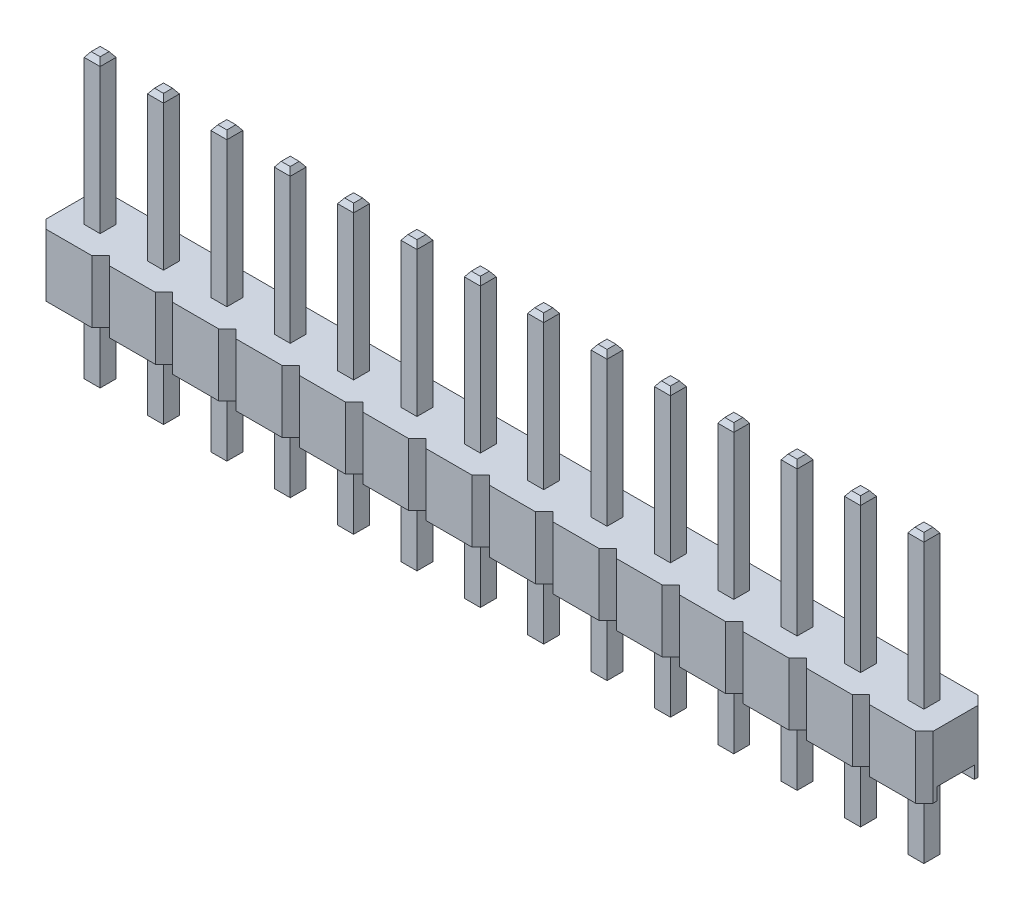
from build123d import *
from OCP.BRepFilletAPI import BRepFilletAPI_MakeChamfer

# Parameters (mm, degrees)
BOSS_EXTRUDE1_DEPTH         = 2.5
SKETCH3_W                   = 2.54
SKETCH3_H                   = 1.5
CUT_EXTRUDE1_DEPTH          = 0.5
BOSS_EXTRUDE2_START         = -5.5
SKETCH4_W                   = 0.64
SKETCH4_H                   = 0.64
BOSS_EXTRUDE2_DEPTH         = 11.5
CHAMFER1_SIZE               = 0.2
CHAMFER1_SIZE2              = 0.140041508
LPATTERN3_COUNT             = 14
LPATTERN3_PITCH             = 2.54
CHAMFER1_OF_LPATTERN3_SIZE  = 0.2
CHAMFER1_OF_LPATTERN3_SIZE2 = 0.140041508


with BuildPart() as part:
    # Sketch1 → Boss-Extrude1 (new body)
    with BuildSketch(Plane(origin=(0, 0, 0), x_dir=(1, 0, 0), z_dir=(0, 1, 0))):
        Polygon((0, 2.15), (0.35, 2.5), (2.19, 2.5), (2.54, 2.15), (2.54, 0.35), (2.19, 0), (0.35, 0), (0, 0.35), align=None)
    boss_extrude1 = extrude(amount=BOSS_EXTRUDE1_DEPTH)

    # Sketch3 → Cut-Extrude1 (cut)
    with BuildSketch(Plane.XZ):
        with Locations((1.27, -1.25)):
            Rectangle(SKETCH3_W, SKETCH3_H)
    cut_extrude1 = extrude(amount=-CUT_EXTRUDE1_DEPTH, mode=Mode.SUBTRACT)

    # Sketch4 → Boss-Extrude2 (add)
    with BuildSketch(Plane(origin=(0, 2.5, 0), x_dir=(1, 0, 0), z_dir=(0, 1, 0)).offset(BOSS_EXTRUDE2_START)):
        with Locations((1.27, 1.25)):
            Rectangle(SKETCH4_W, SKETCH4_H)
    boss_extrude2 = extrude(amount=BOSS_EXTRUDE2_DEPTH)

    # Chamfer1: one chamfer whose edges measure the first distance from different faces: ONE call of the kernel's chamfer builder (chamfer() names one face for all edges)
    chamfer1_edges_1 = [part.edges().sort_by_distance(p)[0] for p in [
        (1.59, -3, -1.25),
        (1.27, -3, -0.93),
        (0.95, -3, -1.25),
        (1.27, -3, -1.57),
    ]]
    chamfer1_side_1 = [part.faces().sort_by_distance(p)[0] for p in [
        (1.27, -3, -1.25),
    ]]
    chamfer1_edges_2 = [part.edges().sort_by_distance(p)[0] for p in [
        (1.59, 8.5, -1.25),
    ]]
    chamfer1_side_2 = [part.faces().sort_by_distance(p)[0] for p in [
        (1.59, 5.5, -1.25),
    ]]
    chamfer1_edges_3 = [part.edges().sort_by_distance(p)[0] for p in [
        (1.27, 8.5, -1.57),
    ]]
    chamfer1_side_3 = [part.faces().sort_by_distance(p)[0] for p in [
        (1.27, 5.5, -1.57),
    ]]
    chamfer1_edges_4 = [part.edges().sort_by_distance(p)[0] for p in [
        (0.95, 8.5, -1.25),
    ]]
    chamfer1_side_4 = [part.faces().sort_by_distance(p)[0] for p in [
        (0.95, 5.5, -1.25),
    ]]
    chamfer1_edges_5 = [part.edges().sort_by_distance(p)[0] for p in [
        (1.27, 8.5, -0.93),
    ]]
    chamfer1_side_5 = [part.faces().sort_by_distance(p)[0] for p in [
        (1.27, 5.5, -0.93),
    ]]
    chamfer1 = BRepFilletAPI_MakeChamfer(part.part.solid().wrapped)
    for e in chamfer1_edges_1:
        chamfer1.Add(CHAMFER1_SIZE, CHAMFER1_SIZE2, e.wrapped, chamfer1_side_1[0].wrapped)  # the first distance lies on this face
    for e in chamfer1_edges_2:
        chamfer1.Add(CHAMFER1_SIZE, CHAMFER1_SIZE2, e.wrapped, chamfer1_side_2[0].wrapped)  # the first distance lies on this face
    for e in chamfer1_edges_3:
        chamfer1.Add(CHAMFER1_SIZE, CHAMFER1_SIZE2, e.wrapped, chamfer1_side_3[0].wrapped)  # the first distance lies on this face
    for e in chamfer1_edges_4:
        chamfer1.Add(CHAMFER1_SIZE, CHAMFER1_SIZE2, e.wrapped, chamfer1_side_4[0].wrapped)  # the first distance lies on this face
    for e in chamfer1_edges_5:
        chamfer1.Add(CHAMFER1_SIZE, CHAMFER1_SIZE2, e.wrapped, chamfer1_side_5[0].wrapped)  # the first distance lies on this face
    add(Compound.cast(chamfer1.Shape()), mode=Mode.REPLACE)

    # LPattern3: Boss-Extrude1, Cut-Extrude1, Boss-Extrude2 ×14
    with Locations(*[(-i * LPATTERN3_PITCH, 0, 0) for i in range(1, LPATTERN3_COUNT)]):
        add(boss_extrude1)
        add(cut_extrude1, mode=Mode.SUBTRACT)
        add(boss_extrude2)

    # Chamfer1 of LPattern3: one chamfer whose edges measure the first distance from different faces: ONE call of the kernel's chamfer builder (chamfer() names one face for all edges)
    chamfer1_of_lpattern3_edges_1 = [part.edges().sort_by_distance(p)[0] for p in [
        (-0.95, -3, -1.25),
        (-1.27, -3, -0.93),
        (-1.59, -3, -1.25),
        (-1.27, -3, -1.57),
    ]]
    chamfer1_of_lpattern3_side_1 = [part.faces().sort_by_distance(p)[0] for p in [
        (-1.27, -3, -1.25),
    ]]
    chamfer1_of_lpattern3_edges_2 = [part.edges().sort_by_distance(p)[0] for p in [
        (-0.95, 8.5, -1.25),
    ]]
    chamfer1_of_lpattern3_side_2 = [part.faces().sort_by_distance(p)[0] for p in [
        (-0.95, 5.5, -1.25),
    ]]
    chamfer1_of_lpattern3_edges_3 = [part.edges().sort_by_distance(p)[0] for p in [
        (-1.27, 8.5, -1.57),
    ]]
    chamfer1_of_lpattern3_side_3 = [part.faces().sort_by_distance(p)[0] for p in [
        (-1.27, 5.5, -1.57),
    ]]
    chamfer1_of_lpattern3_edges_4 = [part.edges().sort_by_distance(p)[0] for p in [
        (-1.59, 8.5, -1.25),
    ]]
    chamfer1_of_lpattern3_side_4 = [part.faces().sort_by_distance(p)[0] for p in [
        (-1.59, 5.5, -1.25),
    ]]
    chamfer1_of_lpattern3_edges_5 = [part.edges().sort_by_distance(p)[0] for p in [
        (-1.27, 8.5, -0.93),
    ]]
    chamfer1_of_lpattern3_side_5 = [part.faces().sort_by_distance(p)[0] for p in [
        (-1.27, 5.5, -0.93),
    ]]
    chamfer1_of_lpattern3_edges_6 = [part.edges().sort_by_distance(p)[0] for p in [
        (-3.49, -3, -1.25),
        (-3.81, -3, -0.93),
        (-4.13, -3, -1.25),
        (-3.81, -3, -1.57),
    ]]
    chamfer1_of_lpattern3_side_6 = [part.faces().sort_by_distance(p)[0] for p in [
        (-3.81, -3, -1.25),
    ]]
    chamfer1_of_lpattern3_edges_7 = [part.edges().sort_by_distance(p)[0] for p in [
        (-3.49, 8.5, -1.25),
    ]]
    chamfer1_of_lpattern3_side_7 = [part.faces().sort_by_distance(p)[0] for p in [
        (-3.49, 5.5, -1.25),
    ]]
    chamfer1_of_lpattern3_edges_8 = [part.edges().sort_by_distance(p)[0] for p in [
        (-3.81, 8.5, -1.57),
    ]]
    chamfer1_of_lpattern3_side_8 = [part.faces().sort_by_distance(p)[0] for p in [
        (-3.81, 5.5, -1.57),
    ]]
    chamfer1_of_lpattern3_edges_9 = [part.edges().sort_by_distance(p)[0] for p in [
        (-4.13, 8.5, -1.25),
    ]]
    chamfer1_of_lpattern3_side_9 = [part.faces().sort_by_distance(p)[0] for p in [
        (-4.13, 5.5, -1.25),
    ]]
    chamfer1_of_lpattern3_edges_10 = [part.edges().sort_by_distance(p)[0] for p in [
        (-3.81, 8.5, -0.93),
    ]]
    chamfer1_of_lpattern3_side_10 = [part.faces().sort_by_distance(p)[0] for p in [
        (-3.81, 5.5, -0.93),
    ]]
    chamfer1_of_lpattern3_edges_11 = [part.edges().sort_by_distance(p)[0] for p in [
        (-6.03, -3, -1.25),
        (-6.35, -3, -0.93),
        (-6.67, -3, -1.25),
        (-6.35, -3, -1.57),
    ]]
    chamfer1_of_lpattern3_side_11 = [part.faces().sort_by_distance(p)[0] for p in [
        (-6.35, -3, -1.25),
    ]]
    chamfer1_of_lpattern3_edges_12 = [part.edges().sort_by_distance(p)[0] for p in [
        (-6.03, 8.5, -1.25),
    ]]
    chamfer1_of_lpattern3_side_12 = [part.faces().sort_by_distance(p)[0] for p in [
        (-6.03, 5.5, -1.25),
    ]]
    chamfer1_of_lpattern3_edges_13 = [part.edges().sort_by_distance(p)[0] for p in [
        (-6.35, 8.5, -1.57),
    ]]
    chamfer1_of_lpattern3_side_13 = [part.faces().sort_by_distance(p)[0] for p in [
        (-6.35, 5.5, -1.57),
    ]]
    chamfer1_of_lpattern3_edges_14 = [part.edges().sort_by_distance(p)[0] for p in [
        (-6.67, 8.5, -1.25),
    ]]
    chamfer1_of_lpattern3_side_14 = [part.faces().sort_by_distance(p)[0] for p in [
        (-6.67, 5.5, -1.25),
    ]]
    chamfer1_of_lpattern3_edges_15 = [part.edges().sort_by_distance(p)[0] for p in [
        (-6.35, 8.5, -0.93),
    ]]
    chamfer1_of_lpattern3_side_15 = [part.faces().sort_by_distance(p)[0] for p in [
        (-6.35, 5.5, -0.93),
    ]]
    chamfer1_of_lpattern3_edges_16 = [part.edges().sort_by_distance(p)[0] for p in [
        (-8.57, -3, -1.25),
        (-8.89, -3, -0.93),
        (-9.21, -3, -1.25),
        (-8.89, -3, -1.57),
    ]]
    chamfer1_of_lpattern3_side_16 = [part.faces().sort_by_distance(p)[0] for p in [
        (-8.89, -3, -1.25),
    ]]
    chamfer1_of_lpattern3_edges_17 = [part.edges().sort_by_distance(p)[0] for p in [
        (-8.57, 8.5, -1.25),
    ]]
    chamfer1_of_lpattern3_side_17 = [part.faces().sort_by_distance(p)[0] for p in [
        (-8.57, 5.5, -1.25),
    ]]
    chamfer1_of_lpattern3_edges_18 = [part.edges().sort_by_distance(p)[0] for p in [
        (-8.89, 8.5, -1.57),
    ]]
    chamfer1_of_lpattern3_side_18 = [part.faces().sort_by_distance(p)[0] for p in [
        (-8.89, 5.5, -1.57),
    ]]
    chamfer1_of_lpattern3_edges_19 = [part.edges().sort_by_distance(p)[0] for p in [
        (-9.21, 8.5, -1.25),
    ]]
    chamfer1_of_lpattern3_side_19 = [part.faces().sort_by_distance(p)[0] for p in [
        (-9.21, 5.5, -1.25),
    ]]
    chamfer1_of_lpattern3_edges_20 = [part.edges().sort_by_distance(p)[0] for p in [
        (-8.89, 8.5, -0.93),
    ]]
    chamfer1_of_lpattern3_side_20 = [part.faces().sort_by_distance(p)[0] for p in [
        (-8.89, 5.5, -0.93),
    ]]
    chamfer1_of_lpattern3_edges_21 = [part.edges().sort_by_distance(p)[0] for p in [
        (-11.11, -3, -1.25),
        (-11.43, -3, -0.93),
        (-11.75, -3, -1.25),
        (-11.43, -3, -1.57),
    ]]
    chamfer1_of_lpattern3_side_21 = [part.faces().sort_by_distance(p)[0] for p in [
        (-11.43, -3, -1.25),
    ]]
    chamfer1_of_lpattern3_edges_22 = [part.edges().sort_by_distance(p)[0] for p in [
        (-11.11, 8.5, -1.25),
    ]]
    chamfer1_of_lpattern3_side_22 = [part.faces().sort_by_distance(p)[0] for p in [
        (-11.11, 5.5, -1.25),
    ]]
    chamfer1_of_lpattern3_edges_23 = [part.edges().sort_by_distance(p)[0] for p in [
        (-11.43, 8.5, -1.57),
    ]]
    chamfer1_of_lpattern3_side_23 = [part.faces().sort_by_distance(p)[0] for p in [
        (-11.43, 5.5, -1.57),
    ]]
    chamfer1_of_lpattern3_edges_24 = [part.edges().sort_by_distance(p)[0] for p in [
        (-11.75, 8.5, -1.25),
    ]]
    chamfer1_of_lpattern3_side_24 = [part.faces().sort_by_distance(p)[0] for p in [
        (-11.75, 5.5, -1.25),
    ]]
    chamfer1_of_lpattern3_edges_25 = [part.edges().sort_by_distance(p)[0] for p in [
        (-11.43, 8.5, -0.93),
    ]]
    chamfer1_of_lpattern3_side_25 = [part.faces().sort_by_distance(p)[0] for p in [
        (-11.43, 5.5, -0.93),
    ]]
    chamfer1_of_lpattern3_edges_26 = [part.edges().sort_by_distance(p)[0] for p in [
        (-13.65, -3, -1.25),
        (-13.97, -3, -0.93),
        (-14.29, -3, -1.25),
        (-13.97, -3, -1.57),
    ]]
    chamfer1_of_lpattern3_side_26 = [part.faces().sort_by_distance(p)[0] for p in [
        (-13.97, -3, -1.25),
    ]]
    chamfer1_of_lpattern3_edges_27 = [part.edges().sort_by_distance(p)[0] for p in [
        (-13.65, 8.5, -1.25),
    ]]
    chamfer1_of_lpattern3_side_27 = [part.faces().sort_by_distance(p)[0] for p in [
        (-13.65, 5.5, -1.25),
    ]]
    chamfer1_of_lpattern3_edges_28 = [part.edges().sort_by_distance(p)[0] for p in [
        (-13.97, 8.5, -1.57),
    ]]
    chamfer1_of_lpattern3_side_28 = [part.faces().sort_by_distance(p)[0] for p in [
        (-13.97, 5.5, -1.57),
    ]]
    chamfer1_of_lpattern3_edges_29 = [part.edges().sort_by_distance(p)[0] for p in [
        (-14.29, 8.5, -1.25),
    ]]
    chamfer1_of_lpattern3_side_29 = [part.faces().sort_by_distance(p)[0] for p in [
        (-14.29, 5.5, -1.25),
    ]]
    chamfer1_of_lpattern3_edges_30 = [part.edges().sort_by_distance(p)[0] for p in [
        (-13.97, 8.5, -0.93),
    ]]
    chamfer1_of_lpattern3_side_30 = [part.faces().sort_by_distance(p)[0] for p in [
        (-13.97, 5.5, -0.93),
    ]]
    chamfer1_of_lpattern3_edges_31 = [part.edges().sort_by_distance(p)[0] for p in [
        (-16.19, -3, -1.25),
        (-16.51, -3, -0.93),
        (-16.83, -3, -1.25),
        (-16.51, -3, -1.57),
    ]]
    chamfer1_of_lpattern3_side_31 = [part.faces().sort_by_distance(p)[0] for p in [
        (-16.51, -3, -1.25),
    ]]
    chamfer1_of_lpattern3_edges_32 = [part.edges().sort_by_distance(p)[0] for p in [
        (-16.19, 8.5, -1.25),
    ]]
    chamfer1_of_lpattern3_side_32 = [part.faces().sort_by_distance(p)[0] for p in [
        (-16.19, 5.5, -1.25),
    ]]
    chamfer1_of_lpattern3_edges_33 = [part.edges().sort_by_distance(p)[0] for p in [
        (-16.51, 8.5, -1.57),
    ]]
    chamfer1_of_lpattern3_side_33 = [part.faces().sort_by_distance(p)[0] for p in [
        (-16.51, 5.5, -1.57),
    ]]
    chamfer1_of_lpattern3_edges_34 = [part.edges().sort_by_distance(p)[0] for p in [
        (-16.83, 8.5, -1.25),
    ]]
    chamfer1_of_lpattern3_side_34 = [part.faces().sort_by_distance(p)[0] for p in [
        (-16.83, 5.5, -1.25),
    ]]
    chamfer1_of_lpattern3_edges_35 = [part.edges().sort_by_distance(p)[0] for p in [
        (-16.51, 8.5, -0.93),
    ]]
    chamfer1_of_lpattern3_side_35 = [part.faces().sort_by_distance(p)[0] for p in [
        (-16.51, 5.5, -0.93),
    ]]
    chamfer1_of_lpattern3_edges_36 = [part.edges().sort_by_distance(p)[0] for p in [
        (-18.73, -3, -1.25),
        (-19.05, -3, -0.93),
        (-19.37, -3, -1.25),
        (-19.05, -3, -1.57),
    ]]
    chamfer1_of_lpattern3_side_36 = [part.faces().sort_by_distance(p)[0] for p in [
        (-19.05, -3, -1.25),
    ]]
    chamfer1_of_lpattern3_edges_37 = [part.edges().sort_by_distance(p)[0] for p in [
        (-18.73, 8.5, -1.25),
    ]]
    chamfer1_of_lpattern3_side_37 = [part.faces().sort_by_distance(p)[0] for p in [
        (-18.73, 5.5, -1.25),
    ]]
    chamfer1_of_lpattern3_edges_38 = [part.edges().sort_by_distance(p)[0] for p in [
        (-19.05, 8.5, -1.57),
    ]]
    chamfer1_of_lpattern3_side_38 = [part.faces().sort_by_distance(p)[0] for p in [
        (-19.05, 5.5, -1.57),
    ]]
    chamfer1_of_lpattern3_edges_39 = [part.edges().sort_by_distance(p)[0] for p in [
        (-19.37, 8.5, -1.25),
    ]]
    chamfer1_of_lpattern3_side_39 = [part.faces().sort_by_distance(p)[0] for p in [
        (-19.37, 5.5, -1.25),
    ]]
    chamfer1_of_lpattern3_edges_40 = [part.edges().sort_by_distance(p)[0] for p in [
        (-19.05, 8.5, -0.93),
    ]]
    chamfer1_of_lpattern3_side_40 = [part.faces().sort_by_distance(p)[0] for p in [
        (-19.05, 5.5, -0.93),
    ]]
    chamfer1_of_lpattern3_edges_41 = [part.edges().sort_by_distance(p)[0] for p in [
        (-21.27, -3, -1.25),
        (-21.59, -3, -0.93),
        (-21.91, -3, -1.25),
        (-21.59, -3, -1.57),
    ]]
    chamfer1_of_lpattern3_side_41 = [part.faces().sort_by_distance(p)[0] for p in [
        (-21.59, -3, -1.25),
    ]]
    chamfer1_of_lpattern3_edges_42 = [part.edges().sort_by_distance(p)[0] for p in [
        (-21.27, 8.5, -1.25),
    ]]
    chamfer1_of_lpattern3_side_42 = [part.faces().sort_by_distance(p)[0] for p in [
        (-21.27, 5.5, -1.25),
    ]]
    chamfer1_of_lpattern3_edges_43 = [part.edges().sort_by_distance(p)[0] for p in [
        (-21.59, 8.5, -1.57),
    ]]
    chamfer1_of_lpattern3_side_43 = [part.faces().sort_by_distance(p)[0] for p in [
        (-21.59, 5.5, -1.57),
    ]]
    chamfer1_of_lpattern3_edges_44 = [part.edges().sort_by_distance(p)[0] for p in [
        (-21.91, 8.5, -1.25),
    ]]
    chamfer1_of_lpattern3_side_44 = [part.faces().sort_by_distance(p)[0] for p in [
        (-21.91, 5.5, -1.25),
    ]]
    chamfer1_of_lpattern3_edges_45 = [part.edges().sort_by_distance(p)[0] for p in [
        (-21.59, 8.5, -0.93),
    ]]
    chamfer1_of_lpattern3_side_45 = [part.faces().sort_by_distance(p)[0] for p in [
        (-21.59, 5.5, -0.93),
    ]]
    chamfer1_of_lpattern3_edges_46 = [part.edges().sort_by_distance(p)[0] for p in [
        (-23.81, -3, -1.25),
        (-24.13, -3, -0.93),
        (-24.45, -3, -1.25),
        (-24.13, -3, -1.57),
    ]]
    chamfer1_of_lpattern3_side_46 = [part.faces().sort_by_distance(p)[0] for p in [
        (-24.13, -3, -1.25),
    ]]
    chamfer1_of_lpattern3_edges_47 = [part.edges().sort_by_distance(p)[0] for p in [
        (-23.81, 8.5, -1.25),
    ]]
    chamfer1_of_lpattern3_side_47 = [part.faces().sort_by_distance(p)[0] for p in [
        (-23.81, 5.5, -1.25),
    ]]
    chamfer1_of_lpattern3_edges_48 = [part.edges().sort_by_distance(p)[0] for p in [
        (-24.13, 8.5, -1.57),
    ]]
    chamfer1_of_lpattern3_side_48 = [part.faces().sort_by_distance(p)[0] for p in [
        (-24.13, 5.5, -1.57),
    ]]
    chamfer1_of_lpattern3_edges_49 = [part.edges().sort_by_distance(p)[0] for p in [
        (-24.45, 8.5, -1.25),
    ]]
    chamfer1_of_lpattern3_side_49 = [part.faces().sort_by_distance(p)[0] for p in [
        (-24.45, 5.5, -1.25),
    ]]
    chamfer1_of_lpattern3_edges_50 = [part.edges().sort_by_distance(p)[0] for p in [
        (-24.13, 8.5, -0.93),
    ]]
    chamfer1_of_lpattern3_side_50 = [part.faces().sort_by_distance(p)[0] for p in [
        (-24.13, 5.5, -0.93),
    ]]
    chamfer1_of_lpattern3_edges_51 = [part.edges().sort_by_distance(p)[0] for p in [
        (-26.35, -3, -1.25),
        (-26.67, -3, -0.93),
        (-26.99, -3, -1.25),
        (-26.67, -3, -1.57),
    ]]
    chamfer1_of_lpattern3_side_51 = [part.faces().sort_by_distance(p)[0] for p in [
        (-26.67, -3, -1.25),
    ]]
    chamfer1_of_lpattern3_edges_52 = [part.edges().sort_by_distance(p)[0] for p in [
        (-26.35, 8.5, -1.25),
    ]]
    chamfer1_of_lpattern3_side_52 = [part.faces().sort_by_distance(p)[0] for p in [
        (-26.35, 5.5, -1.25),
    ]]
    chamfer1_of_lpattern3_edges_53 = [part.edges().sort_by_distance(p)[0] for p in [
        (-26.67, 8.5, -1.57),
    ]]
    chamfer1_of_lpattern3_side_53 = [part.faces().sort_by_distance(p)[0] for p in [
        (-26.67, 5.5, -1.57),
    ]]
    chamfer1_of_lpattern3_edges_54 = [part.edges().sort_by_distance(p)[0] for p in [
        (-26.99, 8.5, -1.25),
    ]]
    chamfer1_of_lpattern3_side_54 = [part.faces().sort_by_distance(p)[0] for p in [
        (-26.99, 5.5, -1.25),
    ]]
    chamfer1_of_lpattern3_edges_55 = [part.edges().sort_by_distance(p)[0] for p in [
        (-26.67, 8.5, -0.93),
    ]]
    chamfer1_of_lpattern3_side_55 = [part.faces().sort_by_distance(p)[0] for p in [
        (-26.67, 5.5, -0.93),
    ]]
    chamfer1_of_lpattern3_edges_56 = [part.edges().sort_by_distance(p)[0] for p in [
        (-28.89, -3, -1.25),
        (-29.21, -3, -0.93),
        (-29.53, -3, -1.25),
        (-29.21, -3, -1.57),
    ]]
    chamfer1_of_lpattern3_side_56 = [part.faces().sort_by_distance(p)[0] for p in [
        (-29.21, -3, -1.25),
    ]]
    chamfer1_of_lpattern3_edges_57 = [part.edges().sort_by_distance(p)[0] for p in [
        (-28.89, 8.5, -1.25),
    ]]
    chamfer1_of_lpattern3_side_57 = [part.faces().sort_by_distance(p)[0] for p in [
        (-28.89, 5.5, -1.25),
    ]]
    chamfer1_of_lpattern3_edges_58 = [part.edges().sort_by_distance(p)[0] for p in [
        (-29.21, 8.5, -1.57),
    ]]
    chamfer1_of_lpattern3_side_58 = [part.faces().sort_by_distance(p)[0] for p in [
        (-29.21, 5.5, -1.57),
    ]]
    chamfer1_of_lpattern3_edges_59 = [part.edges().sort_by_distance(p)[0] for p in [
        (-29.53, 8.5, -1.25),
    ]]
    chamfer1_of_lpattern3_side_59 = [part.faces().sort_by_distance(p)[0] for p in [
        (-29.53, 5.5, -1.25),
    ]]
    chamfer1_of_lpattern3_edges_60 = [part.edges().sort_by_distance(p)[0] for p in [
        (-29.21, 8.5, -0.93),
    ]]
    chamfer1_of_lpattern3_side_60 = [part.faces().sort_by_distance(p)[0] for p in [
        (-29.21, 5.5, -0.93),
    ]]
    chamfer1_of_lpattern3_edges_61 = [part.edges().sort_by_distance(p)[0] for p in [
        (-31.43, -3, -1.25),
        (-31.75, -3, -0.93),
        (-32.07, -3, -1.25),
        (-31.75, -3, -1.57),
    ]]
    chamfer1_of_lpattern3_side_61 = [part.faces().sort_by_distance(p)[0] for p in [
        (-31.75, -3, -1.25),
    ]]
    chamfer1_of_lpattern3_edges_62 = [part.edges().sort_by_distance(p)[0] for p in [
        (-31.43, 8.5, -1.25),
    ]]
    chamfer1_of_lpattern3_side_62 = [part.faces().sort_by_distance(p)[0] for p in [
        (-31.43, 5.5, -1.25),
    ]]
    chamfer1_of_lpattern3_edges_63 = [part.edges().sort_by_distance(p)[0] for p in [
        (-31.75, 8.5, -1.57),
    ]]
    chamfer1_of_lpattern3_side_63 = [part.faces().sort_by_distance(p)[0] for p in [
        (-31.75, 5.5, -1.57),
    ]]
    chamfer1_of_lpattern3_edges_64 = [part.edges().sort_by_distance(p)[0] for p in [
        (-32.07, 8.5, -1.25),
    ]]
    chamfer1_of_lpattern3_side_64 = [part.faces().sort_by_distance(p)[0] for p in [
        (-32.07, 5.5, -1.25),
    ]]
    chamfer1_of_lpattern3_edges_65 = [part.edges().sort_by_distance(p)[0] for p in [
        (-31.75, 8.5, -0.93),
    ]]
    chamfer1_of_lpattern3_side_65 = [part.faces().sort_by_distance(p)[0] for p in [
        (-31.75, 5.5, -0.93),
    ]]
    chamfer1_of_lpattern3 = BRepFilletAPI_MakeChamfer(part.part.solid().wrapped)
    for e in chamfer1_of_lpattern3_edges_1:
        chamfer1_of_lpattern3.Add(CHAMFER1_OF_LPATTERN3_SIZE, CHAMFER1_OF_LPATTERN3_SIZE2, e.wrapped, chamfer1_of_lpattern3_side_1[0].wrapped)  # the first distance lies on this face
    for e in chamfer1_of_lpattern3_edges_2:
        chamfer1_of_lpattern3.Add(CHAMFER1_OF_LPATTERN3_SIZE, CHAMFER1_OF_LPATTERN3_SIZE2, e.wrapped, chamfer1_of_lpattern3_side_2[0].wrapped)  # the first distance lies on this face
    for e in chamfer1_of_lpattern3_edges_3:
        chamfer1_of_lpattern3.Add(CHAMFER1_OF_LPATTERN3_SIZE, CHAMFER1_OF_LPATTERN3_SIZE2, e.wrapped, chamfer1_of_lpattern3_side_3[0].wrapped)  # the first distance lies on this face
    for e in chamfer1_of_lpattern3_edges_4:
        chamfer1_of_lpattern3.Add(CHAMFER1_OF_LPATTERN3_SIZE, CHAMFER1_OF_LPATTERN3_SIZE2, e.wrapped, chamfer1_of_lpattern3_side_4[0].wrapped)  # the first distance lies on this face
    for e in chamfer1_of_lpattern3_edges_5:
        chamfer1_of_lpattern3.Add(CHAMFER1_OF_LPATTERN3_SIZE, CHAMFER1_OF_LPATTERN3_SIZE2, e.wrapped, chamfer1_of_lpattern3_side_5[0].wrapped)  # the first distance lies on this face
    for e in chamfer1_of_lpattern3_edges_6:
        chamfer1_of_lpattern3.Add(CHAMFER1_OF_LPATTERN3_SIZE, CHAMFER1_OF_LPATTERN3_SIZE2, e.wrapped, chamfer1_of_lpattern3_side_6[0].wrapped)  # the first distance lies on this face
    for e in chamfer1_of_lpattern3_edges_7:
        chamfer1_of_lpattern3.Add(CHAMFER1_OF_LPATTERN3_SIZE, CHAMFER1_OF_LPATTERN3_SIZE2, e.wrapped, chamfer1_of_lpattern3_side_7[0].wrapped)  # the first distance lies on this face
    for e in chamfer1_of_lpattern3_edges_8:
        chamfer1_of_lpattern3.Add(CHAMFER1_OF_LPATTERN3_SIZE, CHAMFER1_OF_LPATTERN3_SIZE2, e.wrapped, chamfer1_of_lpattern3_side_8[0].wrapped)  # the first distance lies on this face
    for e in chamfer1_of_lpattern3_edges_9:
        chamfer1_of_lpattern3.Add(CHAMFER1_OF_LPATTERN3_SIZE, CHAMFER1_OF_LPATTERN3_SIZE2, e.wrapped, chamfer1_of_lpattern3_side_9[0].wrapped)  # the first distance lies on this face
    for e in chamfer1_of_lpattern3_edges_10:
        chamfer1_of_lpattern3.Add(CHAMFER1_OF_LPATTERN3_SIZE, CHAMFER1_OF_LPATTERN3_SIZE2, e.wrapped, chamfer1_of_lpattern3_side_10[0].wrapped)  # the first distance lies on this face
    for e in chamfer1_of_lpattern3_edges_11:
        chamfer1_of_lpattern3.Add(CHAMFER1_OF_LPATTERN3_SIZE, CHAMFER1_OF_LPATTERN3_SIZE2, e.wrapped, chamfer1_of_lpattern3_side_11[0].wrapped)  # the first distance lies on this face
    for e in chamfer1_of_lpattern3_edges_12:
        chamfer1_of_lpattern3.Add(CHAMFER1_OF_LPATTERN3_SIZE, CHAMFER1_OF_LPATTERN3_SIZE2, e.wrapped, chamfer1_of_lpattern3_side_12[0].wrapped)  # the first distance lies on this face
    for e in chamfer1_of_lpattern3_edges_13:
        chamfer1_of_lpattern3.Add(CHAMFER1_OF_LPATTERN3_SIZE, CHAMFER1_OF_LPATTERN3_SIZE2, e.wrapped, chamfer1_of_lpattern3_side_13[0].wrapped)  # the first distance lies on this face
    for e in chamfer1_of_lpattern3_edges_14:
        chamfer1_of_lpattern3.Add(CHAMFER1_OF_LPATTERN3_SIZE, CHAMFER1_OF_LPATTERN3_SIZE2, e.wrapped, chamfer1_of_lpattern3_side_14[0].wrapped)  # the first distance lies on this face
    for e in chamfer1_of_lpattern3_edges_15:
        chamfer1_of_lpattern3.Add(CHAMFER1_OF_LPATTERN3_SIZE, CHAMFER1_OF_LPATTERN3_SIZE2, e.wrapped, chamfer1_of_lpattern3_side_15[0].wrapped)  # the first distance lies on this face
    for e in chamfer1_of_lpattern3_edges_16:
        chamfer1_of_lpattern3.Add(CHAMFER1_OF_LPATTERN3_SIZE, CHAMFER1_OF_LPATTERN3_SIZE2, e.wrapped, chamfer1_of_lpattern3_side_16[0].wrapped)  # the first distance lies on this face
    for e in chamfer1_of_lpattern3_edges_17:
        chamfer1_of_lpattern3.Add(CHAMFER1_OF_LPATTERN3_SIZE, CHAMFER1_OF_LPATTERN3_SIZE2, e.wrapped, chamfer1_of_lpattern3_side_17[0].wrapped)  # the first distance lies on this face
    for e in chamfer1_of_lpattern3_edges_18:
        chamfer1_of_lpattern3.Add(CHAMFER1_OF_LPATTERN3_SIZE, CHAMFER1_OF_LPATTERN3_SIZE2, e.wrapped, chamfer1_of_lpattern3_side_18[0].wrapped)  # the first distance lies on this face
    for e in chamfer1_of_lpattern3_edges_19:
        chamfer1_of_lpattern3.Add(CHAMFER1_OF_LPATTERN3_SIZE, CHAMFER1_OF_LPATTERN3_SIZE2, e.wrapped, chamfer1_of_lpattern3_side_19[0].wrapped)  # the first distance lies on this face
    for e in chamfer1_of_lpattern3_edges_20:
        chamfer1_of_lpattern3.Add(CHAMFER1_OF_LPATTERN3_SIZE, CHAMFER1_OF_LPATTERN3_SIZE2, e.wrapped, chamfer1_of_lpattern3_side_20[0].wrapped)  # the first distance lies on this face
    for e in chamfer1_of_lpattern3_edges_21:
        chamfer1_of_lpattern3.Add(CHAMFER1_OF_LPATTERN3_SIZE, CHAMFER1_OF_LPATTERN3_SIZE2, e.wrapped, chamfer1_of_lpattern3_side_21[0].wrapped)  # the first distance lies on this face
    for e in chamfer1_of_lpattern3_edges_22:
        chamfer1_of_lpattern3.Add(CHAMFER1_OF_LPATTERN3_SIZE, CHAMFER1_OF_LPATTERN3_SIZE2, e.wrapped, chamfer1_of_lpattern3_side_22[0].wrapped)  # the first distance lies on this face
    for e in chamfer1_of_lpattern3_edges_23:
        chamfer1_of_lpattern3.Add(CHAMFER1_OF_LPATTERN3_SIZE, CHAMFER1_OF_LPATTERN3_SIZE2, e.wrapped, chamfer1_of_lpattern3_side_23[0].wrapped)  # the first distance lies on this face
    for e in chamfer1_of_lpattern3_edges_24:
        chamfer1_of_lpattern3.Add(CHAMFER1_OF_LPATTERN3_SIZE, CHAMFER1_OF_LPATTERN3_SIZE2, e.wrapped, chamfer1_of_lpattern3_side_24[0].wrapped)  # the first distance lies on this face
    for e in chamfer1_of_lpattern3_edges_25:
        chamfer1_of_lpattern3.Add(CHAMFER1_OF_LPATTERN3_SIZE, CHAMFER1_OF_LPATTERN3_SIZE2, e.wrapped, chamfer1_of_lpattern3_side_25[0].wrapped)  # the first distance lies on this face
    for e in chamfer1_of_lpattern3_edges_26:
        chamfer1_of_lpattern3.Add(CHAMFER1_OF_LPATTERN3_SIZE, CHAMFER1_OF_LPATTERN3_SIZE2, e.wrapped, chamfer1_of_lpattern3_side_26[0].wrapped)  # the first distance lies on this face
    for e in chamfer1_of_lpattern3_edges_27:
        chamfer1_of_lpattern3.Add(CHAMFER1_OF_LPATTERN3_SIZE, CHAMFER1_OF_LPATTERN3_SIZE2, e.wrapped, chamfer1_of_lpattern3_side_27[0].wrapped)  # the first distance lies on this face
    for e in chamfer1_of_lpattern3_edges_28:
        chamfer1_of_lpattern3.Add(CHAMFER1_OF_LPATTERN3_SIZE, CHAMFER1_OF_LPATTERN3_SIZE2, e.wrapped, chamfer1_of_lpattern3_side_28[0].wrapped)  # the first distance lies on this face
    for e in chamfer1_of_lpattern3_edges_29:
        chamfer1_of_lpattern3.Add(CHAMFER1_OF_LPATTERN3_SIZE, CHAMFER1_OF_LPATTERN3_SIZE2, e.wrapped, chamfer1_of_lpattern3_side_29[0].wrapped)  # the first distance lies on this face
    for e in chamfer1_of_lpattern3_edges_30:
        chamfer1_of_lpattern3.Add(CHAMFER1_OF_LPATTERN3_SIZE, CHAMFER1_OF_LPATTERN3_SIZE2, e.wrapped, chamfer1_of_lpattern3_side_30[0].wrapped)  # the first distance lies on this face
    for e in chamfer1_of_lpattern3_edges_31:
        chamfer1_of_lpattern3.Add(CHAMFER1_OF_LPATTERN3_SIZE, CHAMFER1_OF_LPATTERN3_SIZE2, e.wrapped, chamfer1_of_lpattern3_side_31[0].wrapped)  # the first distance lies on this face
    for e in chamfer1_of_lpattern3_edges_32:
        chamfer1_of_lpattern3.Add(CHAMFER1_OF_LPATTERN3_SIZE, CHAMFER1_OF_LPATTERN3_SIZE2, e.wrapped, chamfer1_of_lpattern3_side_32[0].wrapped)  # the first distance lies on this face
    for e in chamfer1_of_lpattern3_edges_33:
        chamfer1_of_lpattern3.Add(CHAMFER1_OF_LPATTERN3_SIZE, CHAMFER1_OF_LPATTERN3_SIZE2, e.wrapped, chamfer1_of_lpattern3_side_33[0].wrapped)  # the first distance lies on this face
    for e in chamfer1_of_lpattern3_edges_34:
        chamfer1_of_lpattern3.Add(CHAMFER1_OF_LPATTERN3_SIZE, CHAMFER1_OF_LPATTERN3_SIZE2, e.wrapped, chamfer1_of_lpattern3_side_34[0].wrapped)  # the first distance lies on this face
    for e in chamfer1_of_lpattern3_edges_35:
        chamfer1_of_lpattern3.Add(CHAMFER1_OF_LPATTERN3_SIZE, CHAMFER1_OF_LPATTERN3_SIZE2, e.wrapped, chamfer1_of_lpattern3_side_35[0].wrapped)  # the first distance lies on this face
    for e in chamfer1_of_lpattern3_edges_36:
        chamfer1_of_lpattern3.Add(CHAMFER1_OF_LPATTERN3_SIZE, CHAMFER1_OF_LPATTERN3_SIZE2, e.wrapped, chamfer1_of_lpattern3_side_36[0].wrapped)  # the first distance lies on this face
    for e in chamfer1_of_lpattern3_edges_37:
        chamfer1_of_lpattern3.Add(CHAMFER1_OF_LPATTERN3_SIZE, CHAMFER1_OF_LPATTERN3_SIZE2, e.wrapped, chamfer1_of_lpattern3_side_37[0].wrapped)  # the first distance lies on this face
    for e in chamfer1_of_lpattern3_edges_38:
        chamfer1_of_lpattern3.Add(CHAMFER1_OF_LPATTERN3_SIZE, CHAMFER1_OF_LPATTERN3_SIZE2, e.wrapped, chamfer1_of_lpattern3_side_38[0].wrapped)  # the first distance lies on this face
    for e in chamfer1_of_lpattern3_edges_39:
        chamfer1_of_lpattern3.Add(CHAMFER1_OF_LPATTERN3_SIZE, CHAMFER1_OF_LPATTERN3_SIZE2, e.wrapped, chamfer1_of_lpattern3_side_39[0].wrapped)  # the first distance lies on this face
    for e in chamfer1_of_lpattern3_edges_40:
        chamfer1_of_lpattern3.Add(CHAMFER1_OF_LPATTERN3_SIZE, CHAMFER1_OF_LPATTERN3_SIZE2, e.wrapped, chamfer1_of_lpattern3_side_40[0].wrapped)  # the first distance lies on this face
    for e in chamfer1_of_lpattern3_edges_41:
        chamfer1_of_lpattern3.Add(CHAMFER1_OF_LPATTERN3_SIZE, CHAMFER1_OF_LPATTERN3_SIZE2, e.wrapped, chamfer1_of_lpattern3_side_41[0].wrapped)  # the first distance lies on this face
    for e in chamfer1_of_lpattern3_edges_42:
        chamfer1_of_lpattern3.Add(CHAMFER1_OF_LPATTERN3_SIZE, CHAMFER1_OF_LPATTERN3_SIZE2, e.wrapped, chamfer1_of_lpattern3_side_42[0].wrapped)  # the first distance lies on this face
    for e in chamfer1_of_lpattern3_edges_43:
        chamfer1_of_lpattern3.Add(CHAMFER1_OF_LPATTERN3_SIZE, CHAMFER1_OF_LPATTERN3_SIZE2, e.wrapped, chamfer1_of_lpattern3_side_43[0].wrapped)  # the first distance lies on this face
    for e in chamfer1_of_lpattern3_edges_44:
        chamfer1_of_lpattern3.Add(CHAMFER1_OF_LPATTERN3_SIZE, CHAMFER1_OF_LPATTERN3_SIZE2, e.wrapped, chamfer1_of_lpattern3_side_44[0].wrapped)  # the first distance lies on this face
    for e in chamfer1_of_lpattern3_edges_45:
        chamfer1_of_lpattern3.Add(CHAMFER1_OF_LPATTERN3_SIZE, CHAMFER1_OF_LPATTERN3_SIZE2, e.wrapped, chamfer1_of_lpattern3_side_45[0].wrapped)  # the first distance lies on this face
    for e in chamfer1_of_lpattern3_edges_46:
        chamfer1_of_lpattern3.Add(CHAMFER1_OF_LPATTERN3_SIZE, CHAMFER1_OF_LPATTERN3_SIZE2, e.wrapped, chamfer1_of_lpattern3_side_46[0].wrapped)  # the first distance lies on this face
    for e in chamfer1_of_lpattern3_edges_47:
        chamfer1_of_lpattern3.Add(CHAMFER1_OF_LPATTERN3_SIZE, CHAMFER1_OF_LPATTERN3_SIZE2, e.wrapped, chamfer1_of_lpattern3_side_47[0].wrapped)  # the first distance lies on this face
    for e in chamfer1_of_lpattern3_edges_48:
        chamfer1_of_lpattern3.Add(CHAMFER1_OF_LPATTERN3_SIZE, CHAMFER1_OF_LPATTERN3_SIZE2, e.wrapped, chamfer1_of_lpattern3_side_48[0].wrapped)  # the first distance lies on this face
    for e in chamfer1_of_lpattern3_edges_49:
        chamfer1_of_lpattern3.Add(CHAMFER1_OF_LPATTERN3_SIZE, CHAMFER1_OF_LPATTERN3_SIZE2, e.wrapped, chamfer1_of_lpattern3_side_49[0].wrapped)  # the first distance lies on this face
    for e in chamfer1_of_lpattern3_edges_50:
        chamfer1_of_lpattern3.Add(CHAMFER1_OF_LPATTERN3_SIZE, CHAMFER1_OF_LPATTERN3_SIZE2, e.wrapped, chamfer1_of_lpattern3_side_50[0].wrapped)  # the first distance lies on this face
    for e in chamfer1_of_lpattern3_edges_51:
        chamfer1_of_lpattern3.Add(CHAMFER1_OF_LPATTERN3_SIZE, CHAMFER1_OF_LPATTERN3_SIZE2, e.wrapped, chamfer1_of_lpattern3_side_51[0].wrapped)  # the first distance lies on this face
    for e in chamfer1_of_lpattern3_edges_52:
        chamfer1_of_lpattern3.Add(CHAMFER1_OF_LPATTERN3_SIZE, CHAMFER1_OF_LPATTERN3_SIZE2, e.wrapped, chamfer1_of_lpattern3_side_52[0].wrapped)  # the first distance lies on this face
    for e in chamfer1_of_lpattern3_edges_53:
        chamfer1_of_lpattern3.Add(CHAMFER1_OF_LPATTERN3_SIZE, CHAMFER1_OF_LPATTERN3_SIZE2, e.wrapped, chamfer1_of_lpattern3_side_53[0].wrapped)  # the first distance lies on this face
    for e in chamfer1_of_lpattern3_edges_54:
        chamfer1_of_lpattern3.Add(CHAMFER1_OF_LPATTERN3_SIZE, CHAMFER1_OF_LPATTERN3_SIZE2, e.wrapped, chamfer1_of_lpattern3_side_54[0].wrapped)  # the first distance lies on this face
    for e in chamfer1_of_lpattern3_edges_55:
        chamfer1_of_lpattern3.Add(CHAMFER1_OF_LPATTERN3_SIZE, CHAMFER1_OF_LPATTERN3_SIZE2, e.wrapped, chamfer1_of_lpattern3_side_55[0].wrapped)  # the first distance lies on this face
    for e in chamfer1_of_lpattern3_edges_56:
        chamfer1_of_lpattern3.Add(CHAMFER1_OF_LPATTERN3_SIZE, CHAMFER1_OF_LPATTERN3_SIZE2, e.wrapped, chamfer1_of_lpattern3_side_56[0].wrapped)  # the first distance lies on this face
    for e in chamfer1_of_lpattern3_edges_57:
        chamfer1_of_lpattern3.Add(CHAMFER1_OF_LPATTERN3_SIZE, CHAMFER1_OF_LPATTERN3_SIZE2, e.wrapped, chamfer1_of_lpattern3_side_57[0].wrapped)  # the first distance lies on this face
    for e in chamfer1_of_lpattern3_edges_58:
        chamfer1_of_lpattern3.Add(CHAMFER1_OF_LPATTERN3_SIZE, CHAMFER1_OF_LPATTERN3_SIZE2, e.wrapped, chamfer1_of_lpattern3_side_58[0].wrapped)  # the first distance lies on this face
    for e in chamfer1_of_lpattern3_edges_59:
        chamfer1_of_lpattern3.Add(CHAMFER1_OF_LPATTERN3_SIZE, CHAMFER1_OF_LPATTERN3_SIZE2, e.wrapped, chamfer1_of_lpattern3_side_59[0].wrapped)  # the first distance lies on this face
    for e in chamfer1_of_lpattern3_edges_60:
        chamfer1_of_lpattern3.Add(CHAMFER1_OF_LPATTERN3_SIZE, CHAMFER1_OF_LPATTERN3_SIZE2, e.wrapped, chamfer1_of_lpattern3_side_60[0].wrapped)  # the first distance lies on this face
    for e in chamfer1_of_lpattern3_edges_61:
        chamfer1_of_lpattern3.Add(CHAMFER1_OF_LPATTERN3_SIZE, CHAMFER1_OF_LPATTERN3_SIZE2, e.wrapped, chamfer1_of_lpattern3_side_61[0].wrapped)  # the first distance lies on this face
    for e in chamfer1_of_lpattern3_edges_62:
        chamfer1_of_lpattern3.Add(CHAMFER1_OF_LPATTERN3_SIZE, CHAMFER1_OF_LPATTERN3_SIZE2, e.wrapped, chamfer1_of_lpattern3_side_62[0].wrapped)  # the first distance lies on this face
    for e in chamfer1_of_lpattern3_edges_63:
        chamfer1_of_lpattern3.Add(CHAMFER1_OF_LPATTERN3_SIZE, CHAMFER1_OF_LPATTERN3_SIZE2, e.wrapped, chamfer1_of_lpattern3_side_63[0].wrapped)  # the first distance lies on this face
    for e in chamfer1_of_lpattern3_edges_64:
        chamfer1_of_lpattern3.Add(CHAMFER1_OF_LPATTERN3_SIZE, CHAMFER1_OF_LPATTERN3_SIZE2, e.wrapped, chamfer1_of_lpattern3_side_64[0].wrapped)  # the first distance lies on this face
    for e in chamfer1_of_lpattern3_edges_65:
        chamfer1_of_lpattern3.Add(CHAMFER1_OF_LPATTERN3_SIZE, CHAMFER1_OF_LPATTERN3_SIZE2, e.wrapped, chamfer1_of_lpattern3_side_65[0].wrapped)  # the first distance lies on this face
    add(Compound.cast(chamfer1_of_lpattern3.Shape()), mode=Mode.REPLACE)


solid = part.part
